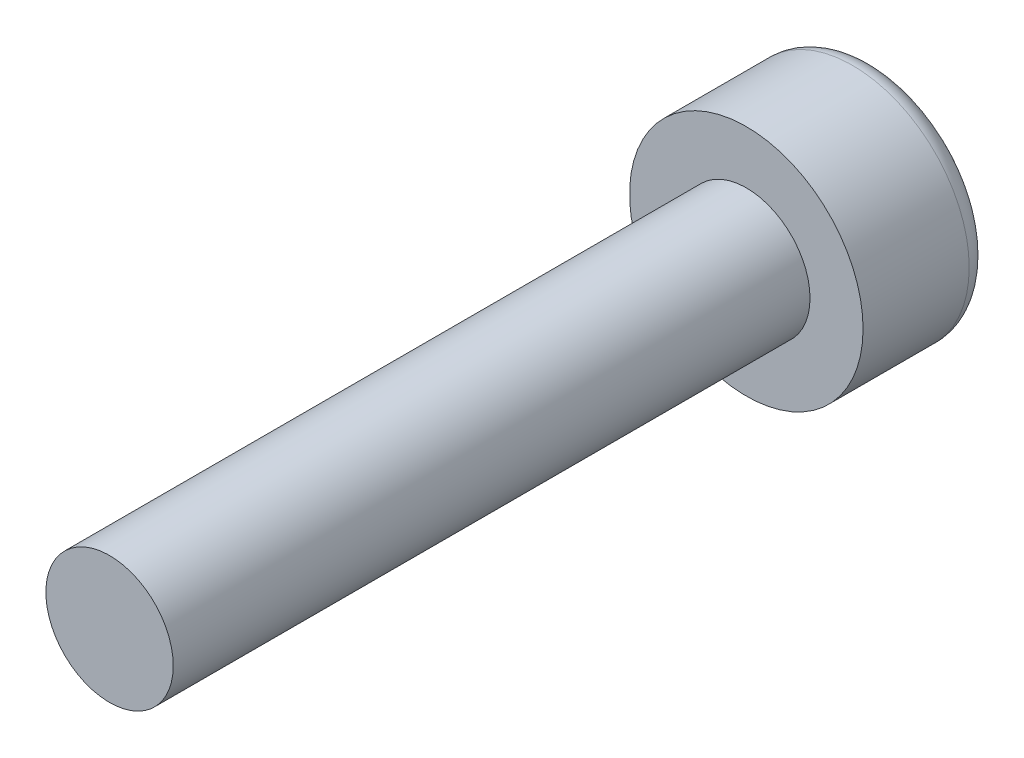
from build123d import *

# Parameters (mm, degrees)
SKETCH_2_R      = 2.75
EXTRUDE_1_DEPTH = 3
SKETCH_3_R      = 1.5
EXTRUDE_2_DEPTH = 15
FILLET_1_R      = 0.5


with BuildPart() as part:
    # ｽｹｯﾁ2 → ﾎﾞｽ - 押し出し1 (new body)
    with BuildSketch(Plane.XY):
        Circle(SKETCH_2_R)
    extrude(amount=EXTRUDE_1_DEPTH)

    # ｽｹｯﾁ3 → ﾎﾞｽ - 押し出し2 (add)
    with BuildSketch(Plane.XY.offset(3)):
        Circle(SKETCH_3_R)
    extrude(amount=EXTRUDE_2_DEPTH)

    # ﾌｨﾚｯﾄ1
    fillet_1_edges = [part.edges().sort_by_distance(p)[0] for p in [
        (-2.75, 0, 0),
    ]]
    fillet(fillet_1_edges, radius=FILLET_1_R)


solid = part.part
